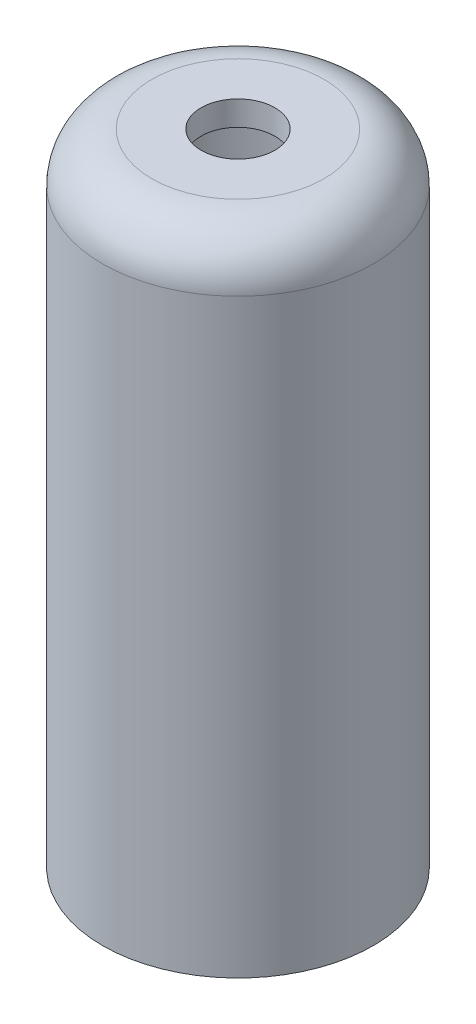
from build123d import *

# Parameters (mm, degrees)
SKETCH1_R           = 17.4625
BOSS_EXTRUDE1_DEPTH = 82.55
SKETCH2_R           = 14.2875
CUT_EXTRUDE1_DEPTH  = 79.375
SKETCH3_R           = 4.7625
CUT_EXTRUDE2_DEPTH  = 83.55
FILLET2_R           = 6.35


with BuildPart() as part:
    # Sketch1 → Boss-Extrude1 (new body)
    with BuildSketch(Plane(origin=(0, 0, 0), x_dir=(1, 0, 0), z_dir=(0, 1, 0))):
        Circle(SKETCH1_R)
    extrude(amount=-BOSS_EXTRUDE1_DEPTH)

    # Sketch2 → Cut-Extrude1 (cut)
    with BuildSketch(Plane.XZ.offset(82.55)):
        Circle(SKETCH2_R)
    extrude(amount=-CUT_EXTRUDE1_DEPTH, mode=Mode.SUBTRACT)

    # Sketch3 → Cut-Extrude2 (cut, through all)
    with BuildSketch(Plane(origin=(0, 0, 0), x_dir=(1, 0, 0), z_dir=(0, 1, 0))):
        Circle(SKETCH3_R)
    extrude(amount=-CUT_EXTRUDE2_DEPTH, mode=Mode.SUBTRACT)

    # Fillet2
    fillet2_edges = [part.edges().sort_by_distance(p)[0] for p in [
        (-17.4625, 0, 0),
    ]]
    fillet(fillet2_edges, radius=FILLET2_R)


solid = part.part
